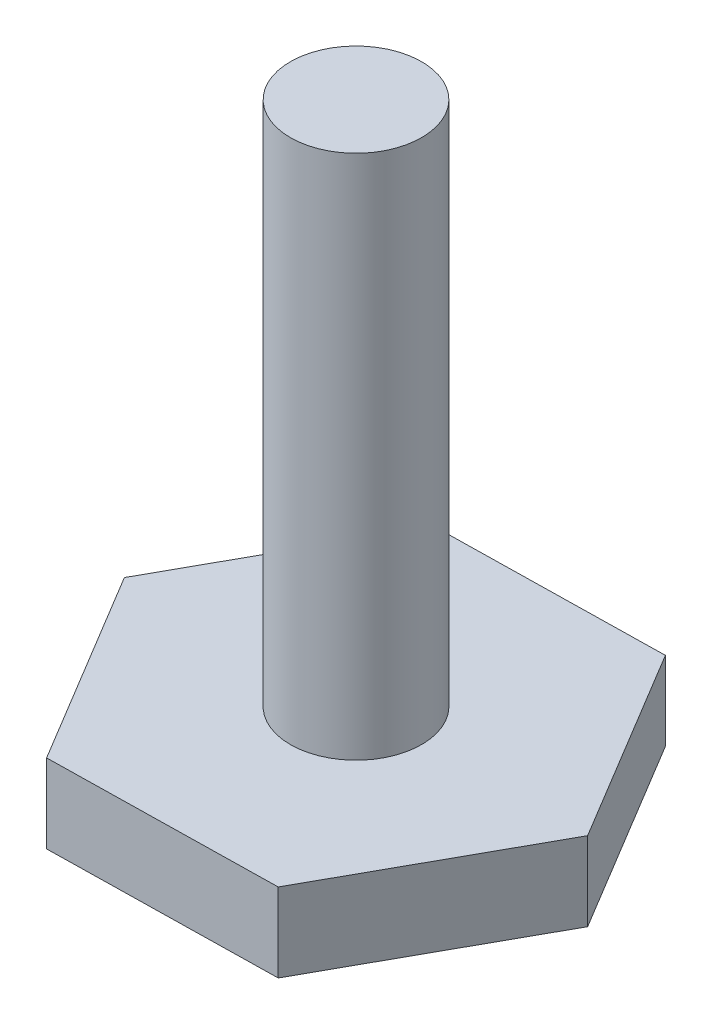
from build123d import *

# Parameters (mm, degrees)
EXTRUDE_1_DEPTH = 12
SKETCH_2_R      = 10
EXTRUDE_2_DEPTH = 80


with BuildPart() as part:
    # 草图1 → 凸台-拉伸1 (new body)
    with BuildSketch(Plane(origin=(0, 0, 0), x_dir=(1, 0, 0), z_dir=(0, 1, 0))):
        Polygon((17.851017883, -29.687390599), (34.635543372, 0.61573967), (16.784525489, 30.303130269), (-17.851017883, 29.687390599), (-34.635543372, -0.61573967), (-16.784525489, -30.303130269), align=None)
    extrude(amount=EXTRUDE_1_DEPTH)

    # 草图2 → 凸台-拉伸2 (add)
    with BuildSketch(Plane(origin=(0, 12, 0), x_dir=(1, 0, 0), z_dir=(0, 1, 0))):
        Circle(SKETCH_2_R)
    extrude(amount=EXTRUDE_2_DEPTH)


solid = part.part
